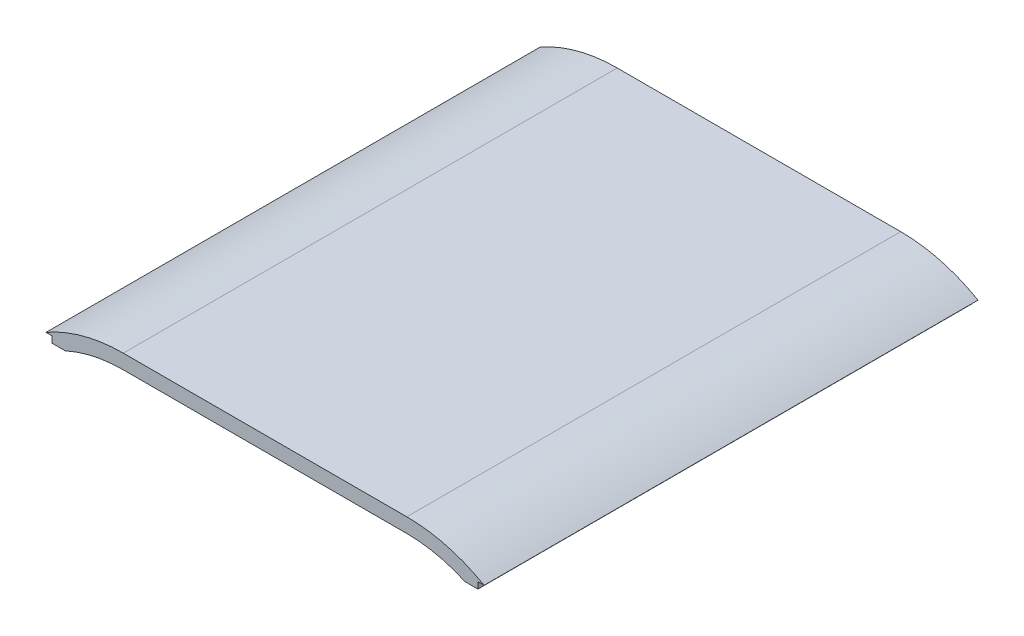
from build123d import *

# Parameters (mm, degrees)
BOSS_EXTRUDE1_DEPTH = 239


with BuildPart() as part:
    # Sketch1 → Boss-Extrude1 (new body)
    with BuildSketch(Plane.XY):
        with BuildLine():
            Line((-68.583426133, 162.213436382), (68.583426132, 162.213436382))
            ThreePointArc((68.583426132, 162.213436382), (87.948342863, 159.670320113), (106, 152.213436382))
            Line((106, 152.213436382), (103, 152.213436382))
            Line((103, 152.213436382), (103, 149.118708113))
            Line((103, 149.118708113), (96.721253554, 149.118708113))
            ThreePointArc((96.721253554, 149.118708113), (82.978590639, 153.67229011), (68.583426132, 155.213436382))
            Line((68.583426132, 155.213436382), (-68.583426133, 155.213436382))
            ThreePointArc((-68.583426133, 155.213436382), (-82.978590639, 153.67229011), (-96.721253554, 149.118708113))
            Line((-96.721253554, 149.118708113), (-103, 149.118708113))
            Line((-103, 149.118708113), (-103, 152.213436382))
            Line((-103, 152.213436382), (-106, 152.213436382))
            ThreePointArc((-106, 152.213436382), (-87.948342864, 159.670320113), (-68.583426133, 162.213436382))
        make_face()
    extrude(amount=BOSS_EXTRUDE1_DEPTH)


solid = part.part
